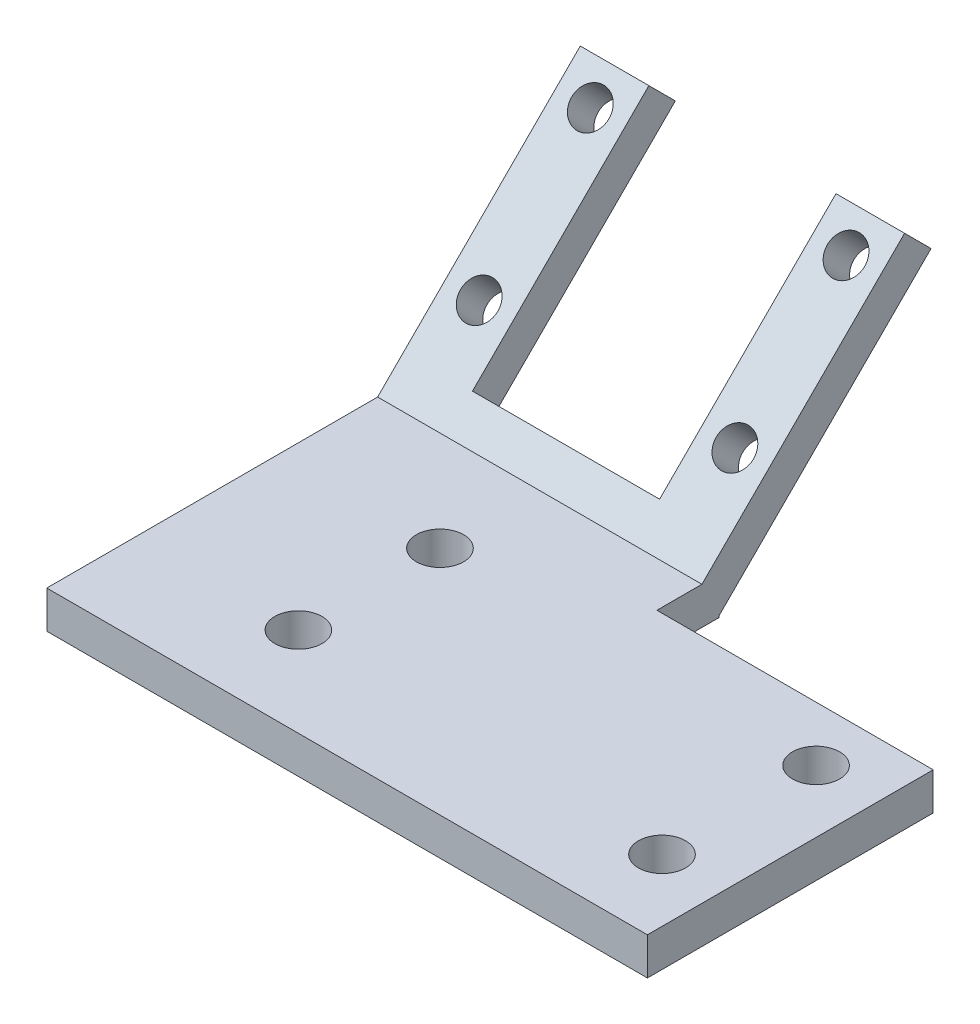
from build123d import *

# Parameters (mm, degrees)
SKETCH2_W           = 48.15
SKETCH2_H           = 26.520901759
SKETCH2_R           = 1.89
BOSS_EXTRUDE1_DEPTH = 3
SKETCH6_R           = 1.5
BOSS_EXTRUDE2_DEPTH = 3
SKETCH7_W           = 26
SKETCH7_H           = 2.377108006
BOSS_EXTRUDE3_DEPTH = 2
SKETCH8_W           = 22.15
SKETCH8_H           = 3.609216989
CUT_EXTRUDE1_DEPTH  = 3


with BuildPart() as part:
    # Sketch2 → Boss-Extrude1 (new body)
    with BuildSketch(Plane(origin=(0, 0, 0), x_dir=(1, 0, 0), z_dir=(0, 1, 0))):
        with Locations((-4, -2.085450879)):
            Rectangle(SKETCH2_W, SKETCH2_H)
        with Locations((-15.075, -8.175)):
            Circle(SKETCH2_R, mode=Mode.SUBTRACT)
        with Locations((-15.075, 3.175)):
            Circle(SKETCH2_R, mode=Mode.SUBTRACT)
        with Locations((15.075, 3.175)):
            Circle(SKETCH2_R, mode=Mode.SUBTRACT)
        with Locations((15.075, -9.175)):
            Circle(SKETCH2_R, mode=Mode.SUBTRACT)
    extrude(amount=BOSS_EXTRUDE1_DEPTH)

    # Sketch6 → Boss-Extrude2 (add)
    with BuildSketch(Plane(origin=(0, -4.0875, -4.0875), x_dir=(-1, 0, 0), z_dir=(0, -0.707106781, -0.707106781))):
        Polygon((2.075, 8.962578452), (28.075, 8.962578452), (28.075, 33), (22.575, 33), (22.575, 13), (7.575, 13), (7.575, 33), (2.075, 33), align=None)
        with Locations((4.825, 17.65)):
            Circle(SKETCH6_R, mode=Mode.SUBTRACT)
        with Locations((25.325, 17.65)):
            Circle(SKETCH6_R, mode=Mode.SUBTRACT)
        with Locations((4.825, 30.25)):
            Circle(SKETCH6_R, mode=Mode.SUBTRACT)
        with Locations((25.325, 30.25)):
            Circle(SKETCH6_R, mode=Mode.SUBTRACT)
    extrude(amount=BOSS_EXTRUDE2_DEPTH)

    # Sketch7 → Boss-Extrude3 (add)
    with BuildSketch(Plane.XZ):
        with Locations((-15.075, -11.357766341)):
            Rectangle(SKETCH7_W, SKETCH7_H)
    extrude(amount=-BOSS_EXTRUDE3_DEPTH)

    # Sketch8 → Cut-Extrude1 (cut)
    with BuildSketch(Plane(origin=(0, 3, 0), x_dir=(1, 0, 0), z_dir=(0, 1, 0))):
        with Locations((9, 9.370391506)):
            Rectangle(SKETCH8_W, SKETCH8_H)
    extrude(amount=-CUT_EXTRUDE1_DEPTH, mode=Mode.SUBTRACT)


solid = part.part
